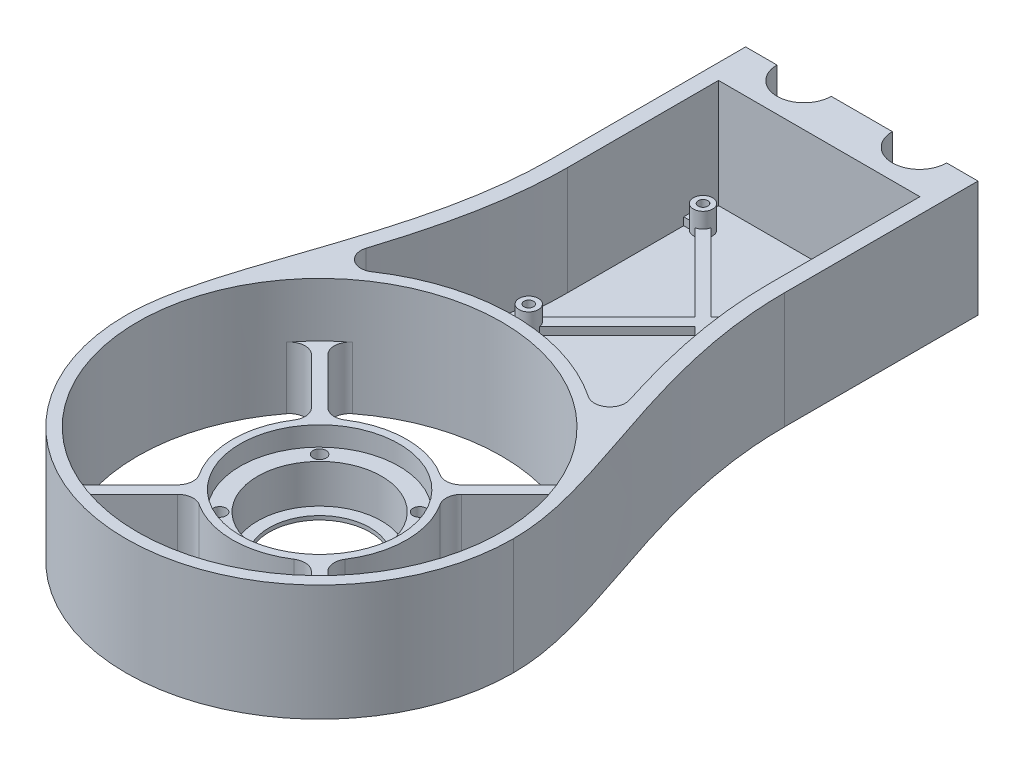
from build123d import *
from build123d.topology import SkipClean

# Parameters (mm, degrees)
EXTRUDE_1_DEPTH            = 30
CUT_EXTRUDE_1_DEPTH        = 209.32703380700454
SKETCH_3_R                 = 22.499999999999996
SKETCH_3_R_2               = 13.000000000000005
EXTRUDE_2_DEPTH            = 16
SKETCH_4_R                 = 20.499999999999996
CUT_EXTRUDE_2_DEPTH        = 5
SKETCH_5_R                 = 16.000000000000007
CUT_EXTRUDE_3_DEPTH        = 10
HOLE_WIZARD_M31_AT_2_COUNT = 2
HOLE_WIZARD_M31_AT_2_PITCH = 25.809397513308994
HOLE_WIZARD_M31_AT_3_COUNT = 2
HOLE_WIZARD_M31_AT_3_PITCH = 36.500000000000036
HOLE_WIZARD_M31_AT_4_COUNT = 2
HOLE_WIZARD_M31_AT_4_PITCH = 25.809397513308866
EXTRUDE_3_DEPTH            = 16
EXTRUDE_4_DEPTH            = 16
FILLET_1_R                 = 4
FILLET_2_R                 = 4
EXTRUDE_5_DEPTH            = 30
EXTRUDE_6_DEPTH            = 14
EXTRUDE_START              = -30
EXTRUDE_7_DEPTH            = 30
CUT_EXTRUDE_4_DEPTH        = 209.32703380700454
EXTRUDE_9_DEPTH            = 30
EXTRUDE_10_DEPTH           = 2
SKETCH_19_R                = 2.4999999999999996
SKETCH_19_R_2              = 2.5000000000000027
SKETCH_19_R_3              = 2.5
EXTRUDE_11_DEPTH           = 6
M3X0_51_D                  = 2.5
M3X0_51_DEPTH              = 6
M3X0_51_TIP                = 0.7510757737844503
EXTRUDE_12_DEPTH           = 2


with BuildPart() as part:
    # Эскиз1 → Бобышка-Вытянуть1 (new body)
    with BuildSketch(Plane(origin=(0, 0, 0), x_dir=(1, 0, 0), z_dir=(0, 1, 0))):
        with BuildLine():
            Line((0, 0), (8.1, 0))
            ThreePointArc((8.1, 0), (15.1, -6.999999999999998), (22.099999999999998, 0))
            Line((22.099999999999998, 0), (37.900000000000006, 0))
            ThreePointArc((37.900000000000006, 0), (44.9, -6.999999999999993), (51.9, 0))
            Line((51.9, 0), (60, 0))
            Line((60, 0), (60, -50))
            add(Edge.make_bspline(
                [(60, -50), (60, -86.11635365077277), (80.16072899532085, -116.6426083985747), (80, -140)],
                knots=[0, 0, 0, 0, 1, 1, 1, 1], degree=3))
            ThreePointArc((80, -140), (29.99999999999999, -190), (-20.000000000000004, -140))
            add(Edge.make_bspline(
                [(0, -50), (0, -86.11635365077277), (-20.160728995320852, -116.6426083985747), (-20.000000000000004, -140)],
                knots=[0, 0, 0, 0, 1, 1, 1, 1], degree=3))
            Line((0, -50), (0, 0))
        make_face()
    extrude(amount=EXTRUDE_1_DEPTH)

    # Эскиз2 → Вырез-Вытянуть1 (cut, through all)
    with BuildSketch(Plane.XZ):
        with BuildLine():
            Line((2.999999999999445, 50.000000000000114), (3, 3))
            Line((3, 3), (5.560607985830544, 3.0000000000000004))
            ThreePointArc((5.560607985830544, 3.0000000000000004), (15.1, 9.999999999999996), (24.639392014169452, 3))
            Line((24.639392014169452, 3), (35.36060798583055, 3.000000000000001))
            ThreePointArc((35.36060798583055, 3.000000000000001), (44.9, 9.999999999999995), (54.43939201416945, 3))
            Line((54.43939201416945, 3), (56.99999999999999, 3.0000000000000004))
            Line((56.99999999999999, 3.0000000000000004), (56.99999999999977, 49.999999999999964))
            add(Edge.make_bspline(
                [(56.99999999999977, 49.999999999999964), (56.999999999999766, 51.15761948444894), (57.04060731241618, 53.481441414304626), (57.273709046009834, 58.05633087995593), (57.83006206428006, 63.68575205723403), (58.858254923149566, 70.27885975955596), (60.62587825488252, 78.85472959222493), (63.422502324744904, 89.16282329636041), (67.22345269691866, 100.85676130834541), (70.98278726548399, 111.85118912341676), (73.68042570475818, 120.39952498600825), (75.34438659158283, 126.83896525592104), (76.29021877948416, 131.46025334650287), (76.78342190294366, 135.12322585437315), (76.97775852866562, 137.9483669686734), (77.0049038165422, 139.30439130408246), (76.99999885765422, 139.9896375455799)],
                knots=[0, 0, 0, 0, 0.03125495533209052, 0.06250991066418103, 0.12501982132836206, 0.18752973199254308, 0.2500396426567241, 0.37505946398508616, 0.5000792853134483, 0.6250991066418103, 0.7501189279701723, 0.8126288386343534, 0.8751387492985344, 0.9376486599627154, 0.968903615294806, 1.0001585706268965, 1.0001585706268965, 1.0001585706268965, 1.0001585706268965], degree=3))
            ThreePointArc((76.99999885765422, 139.9896375455799), (30.000000000044878, 186.99999999999957), (-16.999998857654532, 139.98963754566967))
            add(Edge.make_bspline(
                [(-16.999998857654532, 139.98963754566967), (-17.004903816544154, 139.30439130417213), (-16.977758528670723, 137.94836696876283), (-16.783421902954284, 135.12322585446222), (-16.290218779500016, 131.46025334659032), (-15.34438659160432, 126.83896525600643), (-13.680425704783374, 120.39952498608922), (-10.982787265509687, 111.85118912349087), (-7.223452696941435, 100.85676130840866), (-3.4225023247602575, 89.1628232964107), (-0.6258782548926894, 78.85472959226301), (1.1417450768448598, 70.27885975958334), (2.169937935716575, 63.68575205725274), (2.726290953988904, 58.056330879967035), (2.959392687583103, 53.48144141430967), (2.9999999999994453, 51.1576194844507), (2.999999999999445, 50.000000000000114)],
                knots=[-0.00015857062827955, -0.00015857062827955, -0.00015857062827955, -0.00015857062827955, 0.03109638470385419, 0.06235134003598793, 0.1248612507002554, 0.18737116136452286, 0.24988107202879034, 0.3749008933573253, 0.49992071468586025, 0.6249405360143951, 0.7499603573429301, 0.8124702680071976, 0.874980178671465, 0.9374900893357325, 0.9687450446678663, 1, 1, 1, 1], degree=3))
        make_face()
    extrude(amount=-CUT_EXTRUDE_1_DEPTH, mode=Mode.SUBTRACT)

    # Эскиз9 → Бобышка-Вытянуть3 (add)
    with SkipClean():  # the faces are left unmerged after this step: merging them gives an invalid solid
        with BuildSketch(Plane.XZ):
            with BuildLine():
                ThreePointArc((-10.590299410955694, 110.80363699425222), (29.999999999999805, 89.99999980965572), (70.59029941095437, 110.80363699425268))
                add(Edge.make_bspline(
                    [(70.59029941095437, 110.80363699425268), (70.69273970529346, 111.11282998358755), (71.96821202817154, 114.97382472799917), (73.68042570475818, 120.39952498600825), (75.34438659158283, 126.83896525592104), (76.29021877948416, 131.46025334650287), (76.78342190294366, 135.12322585437315), (76.97775852866562, 137.9483669686734), (77.0049038165422, 139.30439130408246), (76.99999885765422, 139.9896375455799)],
                    knots=[0.6142510234253288, 0.6142510234253288, 0.6142510234253288, 0.6142510234253288, 0.6250991066418103, 0.7501189279701723, 0.8126288386343534, 0.8751387492985344, 0.9376486599627154, 0.968903615294806, 1.0001585706268965, 1.0001585706268965, 1.0001585706268965, 1.0001585706268965], degree=3))
                ThreePointArc((76.99999885765422, 139.9896375455799), (29.99999999995513, 93.00000000000028), (-16.999998857654393, 139.98963754566967))
                add(Edge.make_bspline(
                    [(-16.999998857654393, 139.98963754566967), (-17.004903816544154, 139.30439130417213), (-16.977758528670723, 137.94836696876283), (-16.783421902954284, 135.12322585446222), (-16.290218779500016, 131.46025334659032), (-15.34438659160432, 126.83896525600643), (-13.680425704783374, 120.39952498608922), (-11.968212028189884, 114.97382472805306), (-10.692739705302907, 111.11282998361344), (-10.590299410955694, 110.80363699425222)],
                    knots=[-0.00015857062827955, -0.00015857062827955, -0.00015857062827955, -0.00015857062827955, 0.03109638470385419, 0.06235134003598793, 0.1248612507002554, 0.18737116136452286, 0.24988107202879034, 0.3749008933573253, 0.3857489765746533, 0.3857489765746533, 0.3857489765746533, 0.3857489765746533], degree=3))
            make_face()
        extrude(amount=-EXTRUDE_3_DEPTH)



with BuildPart() as body_2:
    # Эскиз3 → Бобышка-Вытянуть2 (new body)
    with BuildSketch(Plane.XZ):
        with Locations(Location((30, 140, 0), (0, 0, 270))):
            Circle(SKETCH_3_R)
        with Locations(Location((30, 140, 0), (0, 0, 270))):
            Circle(SKETCH_3_R_2, mode=Mode.SUBTRACT)
    extrude(amount=-EXTRUDE_2_DEPTH)

    # Эскиз4 → Вырез-Вытянуть2 (cut)
    with BuildSketch(Plane(origin=(0, 16, 0), x_dir=(1, 0, 0), z_dir=(0, 1, 0))):
        with Locations(Location((30, -140, 0), (0, 0, 270))):
            Circle(SKETCH_4_R)
    extrude(amount=-CUT_EXTRUDE_2_DEPTH, mode=Mode.SUBTRACT)

    # Эскиз5 → Вырез-Вытянуть3 (cut)
    with BuildSketch(Plane(origin=(0, 11, 0), x_dir=(1, 0, 0), z_dir=(0, 1, 0))):
        with Locations(Location((30, -140, 0), (0, 0, 270))):
            Circle(SKETCH_5_R)
    extrude(amount=-CUT_EXTRUDE_3_DEPTH, mode=Mode.SUBTRACT)

    # Эскиз7 → Отверстие с зазором M31 (revolve, cut)
    with BuildSketch(Plane(origin=(17.09530124334549, 11, 127.0953012433455), x_dir=(0, 0, 1), z_dir=(1, 0, 0))):
        Polygon((0, 0), (-2.69e-15, 11), (1.6999999999999966, 11), (1.699999999999988, -1.35e-15), align=None)
    hole_wizard_m31 = revolve(axis=Axis((17.09530124334549, 17.34999999999999, 127.0953012433455), (0, -1, 0)), mode=Mode.SUBTRACT)

    # Отверстие с зазором M31 at 2: Отверстие с зазором M31 ×2
    with Locations(*[(i * HOLE_WIZARD_M31_AT_2_PITCH, 0, 0) for i in range(1, HOLE_WIZARD_M31_AT_2_COUNT)]):
        add(hole_wizard_m31, mode=Mode.SUBTRACT)

    # Отверстие с зазором M31 at 3: Отверстие с зазором M31 ×2
    with Locations(*[Vector(0.7071067811865477, 0, 0.7071067811865475) * (i * HOLE_WIZARD_M31_AT_3_PITCH) for i in range(1, HOLE_WIZARD_M31_AT_3_COUNT)]):
        add(hole_wizard_m31, mode=Mode.SUBTRACT)

    # Отверстие с зазором M31 at 4: Отверстие с зазором M31 ×2
    with Locations(*[(0, 0, i * HOLE_WIZARD_M31_AT_4_PITCH) for i in range(1, HOLE_WIZARD_M31_AT_4_COUNT)]):
        add(hole_wizard_m31, mode=Mode.SUBTRACT)


with BuildPart() as part_1:
    with SkipClean():  # the faces are left unmerged after this step: merging them gives an invalid solid
        add(part.part)

        add(body_2.part)  # Бобышка-Вытянуть4 merges body 2
        # Эскиз10 → Бобышка-Вытянуть4 (add)
        with BuildSketch(Plane.XZ):
            with BuildLine():
                Line((13.061566249611717, 154.81011350677997), (-4.284838091182741, 172.14887054099086))
                ThreePointArc((-4.284838091182741, 172.14887054099086), (-3.2412744710377908, 173.22676137605254), (-2.163839456664804, 174.27079560509063))
                Line((-2.163839456664804, 174.27079560509063), (15.182490993971593, 156.93196464844726))
                ThreePointArc((15.182490993971593, 156.93196464844726), (14.08662392343936, 155.906428318323), (13.061566249611717, 154.81011350677997))
            make_face()
            with BuildLine():
                Line((15.189886493220024, 123.06156624961173), (-2.148870540990859, 105.71516190881728))
                ThreePointArc((-2.148870540990859, 105.71516190881728), (-3.2267613760524867, 106.75872552896217), (-4.270795605090482, 107.83616054333508))
                Line((-4.270795605090482, 107.83616054333508), (13.06803535155281, 125.18249099397156))
                ThreePointArc((13.06803535155281, 125.18249099397156), (14.093571681677025, 124.08662392343936), (15.189886493220024, 123.06156624961173))
            make_face()
            with BuildLine():
                Line((44.81011350677998, 156.9384337503883), (62.14887054099085, 174.2848380911828))
                ThreePointArc((62.14887054099085, 174.2848380911828), (63.22676137605259, 173.24127447103777), (64.27079560509073, 172.1638394566647))
                Line((64.27079560509073, 172.1638394566647), (46.931964648447305, 154.81750900602833))
                ThreePointArc((46.931964648447305, 154.81750900602833), (45.90642831832303, 155.9133760765606), (44.81011350677998, 156.9384337503883))
            make_face()
            with BuildLine():
                Line((46.93843375038829, 125.18988649322004), (64.28483809118275, 107.85112945900916))
                ThreePointArc((64.28483809118275, 107.85112945900916), (63.24127447103766, 106.77323862394736), (62.163839456664554, 105.72920439490919))
                Line((62.163839456664554, 105.72920439490919), (44.81750900602827, 123.06803535155267))
                ThreePointArc((44.81750900602827, 123.06803535155267), (45.91337607656057, 124.09357168167696), (46.93843375038829, 125.18988649322004))
            make_face()
        extrude(amount=-EXTRUDE_4_DEPTH)

    # Скругление1
    fillet_1_edges = [part_1.edges().sort_by_distance(p)[0] for p in [
        (70.59029941095437, 8, 110.80363699425268),
        (-10.590299410955694, 8, 110.80363699425222),
    ]]
    fillet(fillet_1_edges, radius=FILLET_1_R)

    # Скругление2
    fillet_2_edges = [part_1.edges().sort_by_distance(p)[0] for p in [
        (13.068035351552808, 8, 125.18249099397156),
        (-4.270795605090485, 8, 107.83616054333508),
        (13.061566249611715, 8, 154.81011350677997),
        (-4.284838091182738, 8, 172.14887054099086),
        (-2.1638394566648036, 8, 174.27079560509063),
        (15.182490993971593, 8, 156.93196464844726),
        (44.81011350677998, 8, 156.9384337503883),
        (62.148870540990856, 8, 174.2848380911828),
        (46.931964648447305, 8, 154.81750900602833),
        (64.27079560509073, 8, 172.1638394566647),
        (46.93843375038829, 8, 125.18988649322004),
        (64.28483809118275, 8, 107.85112945900917),
        (44.81750900602827, 8, 123.06803535155267),
        (15.189886493220023, 8, 123.06156624961173),
        (-2.1488705409908593, 8, 105.71516190881728),
        (62.16383945666455, 8, 105.72920439490919),
    ]]
    fillet(fillet_2_edges, radius=FILLET_2_R)

    # Эскиз11 → Бобышка-Вытянуть5 (add, through all)
    with BuildSketch(Plane(origin=(0, 30, 0), x_dir=(1, 0, 0), z_dir=(0, 1, 0))):
        with BuildLine():
            ThreePointArc((24.639392014169456, -3.000000000000001), (21.016079755907775, -8.062257768251904), (15.099999932545344, -9.999999999999998))
            Line((15.099999932545344, -9.999999999999998), (44.90000001649191, -9.999999999999998))
            ThreePointArc((44.90000001649191, -9.999999999999995), (38.98392022354849, -8.062257753176917), (35.36060798583055, -3.0000000000000004))
            Line((35.36060798583055, -3.000000000000001), (24.639392014169452, -2.9999999999999996))
        make_face()
        with BuildLine():
            ThreePointArc((54.43939201416945, -3.0000000000000013), (50.81607978974771, -8.062257743420174), (44.90000001649191, -9.999999999999995))
            Line((44.90000001649191, -9.999999999999998), (56.99999999999999, -9.999999999999998))
            Line((56.99999999999999, -9.999999999999998), (56.99999999999999, -3.0000000000000004))
            Line((56.99999999999999, -3.0000000000000004), (54.43939201416945, -3.0000000000000004))
        make_face()
        with BuildLine():
            Line((3.000000000000001, -3.0000000000000027), (3.000000000000001, -9.999999999999998))
            Line((3.000000000000001, -9.999999999999998), (15.099999932545344, -9.999999999999998))
            ThreePointArc((15.099999932545344, -9.999999999999998), (9.183920189708545, -8.062257728345193), (5.560607985830545, -3.0000000000000004))
            Line((5.560607985830544, -3.0000000000000004), (3.000000000000001, -3.0000000000000027))
        make_face()
    extrude(amount=-EXTRUDE_5_DEPTH)

    # Эскиз12 → Бобышка-Вытянуть6 (add)
    with BuildSketch(Plane(origin=(0, 16, 0), x_dir=(1, 0, 0), z_dir=(0, 1, 0))):
        with BuildLine():
            ThreePointArc((59.16935143725943, -99.39028495835004), (29.99999999999936, -89.9999998096564), (0.8306485627395179, -99.39028495835078))
            ThreePointArc((0.8306485627395179, -99.39028495835078), (-3.8552226296420704, -99.37671658564449), (-5.312887214055534, -94.92331486429973))
            add(Edge.make_bspline(
                [(-5.312887214055534, -94.92331486429973), (-5.942237739674335, -96.89165480215254), (-7.843811241515731, -102.67104176506649), (-10.982787265509687, -111.85118912349087), (-13.680425704783374, -120.39952498608922), (-15.34438659160432, -126.83896525600643), (-16.290218779500016, -131.46025334659032), (-16.783421902954284, -135.12322585446222), (-16.977758528670723, -137.94836696876283), (-17.004903816544154, -139.30439130417213), (-16.99999885765474, -139.98963754566967)],
                knots=[-0.00015857062827955, -0.00015857062827955, -0.00015857062827955, -0.00015857062827955, 0.06296962095485116, 0.18798944228338613, 0.31300926361192105, 0.3755191742761885, 0.438029084940456, 0.5005389956047235, 0.5317939509368572, 0.563048906268991, 0.563048906268991, 0.563048906268991, 0.563048906268991], degree=3))
            ThreePointArc((-16.99999885765474, -139.98963754566967), (29.99999999995513, -93.00000000000043), (76.99999885765422, -139.9896375455799))
            add(Edge.make_bspline(
                [(76.99999885765422, -139.9896375455799), (77.0049038165422, -139.30439130408246), (76.97775852866562, -137.9483669686734), (76.78342190294366, -135.12322585437315), (76.29021877948416, -131.46025334650287), (75.34438659158283, -126.83896525592104), (73.68042570475818, -120.39952498600825), (70.98278726548399, -111.85118912341676), (67.84381124149844, -102.67104176501897), (65.94223773966633, -96.89165480213047), (65.31288721405446, -94.92331486429903)],
                knots=[0.4369510937310026, 0.4369510937310026, 0.4369510937310026, 0.4369510937310026, 0.46820604906309315, 0.4994610043951837, 0.5619709150593647, 0.6244808257235457, 0.6869907363877268, 0.8120105577160888, 0.9370303790444509, 1.0001585706268965, 1.0001585706268965, 1.0001585706268965, 1.0001585706268965], degree=3))
            ThreePointArc((65.31288721405446, -94.92331486429903), (63.855222629640906, -99.37671658564365), (59.16935143725943, -99.39028495835004))
        make_face()
    extrude(amount=EXTRUDE_6_DEPTH)

    # Эскиз13 → Бобышка-Вытянуть7 (add)
    with BuildSketch(Plane(origin=(0, 30, 0), x_dir=(1, 0, 0), z_dir=(0, 1, 0)).offset(EXTRUDE_START)):
        with BuildLine():
            Line((3.9999999999992784, -50.0000000000001), (3.999999999999895, -10.999999999999996))
            Line((3.999999999999895, -10.999999999999996), (55.99999999999998, -10.999999999999996))
            Line((55.99999999999998, -10.999999999999996), (55.99999999999991, -49.99999999999998))
            add(Edge.make_bspline(
                [(55.99999999999991, -49.99999999999998), (55.99999999999991, -52.03498068113325), (56.12527058577417, -56.13193535820143), (56.819212399121525, -64.08850039677553), (58.41081044935653, -73.7477782372734), (60.67836350111951, -82.95184755755167), (62.73749964431051, -90.06762105355448), (63.80856926980304, -93.50200234801329), (64.36039029638012, -95.22786309007068)],
                knots=[0, 0, 0, 0, 0.05461888671637527, 0.10923777343275054, 0.21847554686550108, 0.3277133202982516, 0.3823322070146269, 0.43695109373100216, 0.43695109373100216, 0.43695109373100216, 0.43695109373100216], degree=3))
            Line((64.36039029638012, -95.22786309007068), (65.16614916399801, -97.74793305879278))
            ThreePointArc((65.16614916399801, -97.74793305879278), (65.49751290253579, -96.34902670789197), (65.31288721405447, -94.92331486429906))
            add(Edge.make_bspline(
                [(56.99999999999977, -49.999999999999964), (56.999999999999766, -51.15761948444894), (57.04060731241618, -53.481441414304626), (57.273709046009834, -58.05633087995593), (57.83006206428006, -63.68575205723403), (58.858254923149566, -70.27885975955596), (60.62587825488252, -78.85472959222493), (62.85764527026983, -87.08081323654652), (64.69586447452775, -92.99353098181192), (65.31288721405447, -94.92331486429906)],
                knots=[0, 0, 0, 0, 0.03125495533209052, 0.06250991066418103, 0.12501982132836206, 0.18752973199254308, 0.2500396426567241, 0.37505946398508616, 0.4369510937310029, 0.4369510937310029, 0.4369510937310029, 0.4369510937310029], degree=3))
            Line((56.99999999999977, -49.999999999999964), (56.99999999999996, -9.999999999999998))
            Line((56.99999999999996, -9.999999999999998), (2.9999999999999174, -9.999999999999995))
            Line((2.9999999999999174, -9.999999999999995), (2.999999999999445, -50.000000000000114))
            add(Edge.make_bspline(
                [(-5.312887214055517, -94.92331486429967), (-4.695864474533832, -92.99353098182853), (-2.857645270278764, -87.08081323657458), (-0.6258782548926894, -78.85472959226301), (1.1417450768448598, -70.27885975958334), (2.169937935716575, -63.68575205725274), (2.726290953988904, -58.056330879967035), (2.959392687583103, -53.48144141430967), (2.9999999999994453, -51.1576194844507), (2.999999999999445, -50.000000000000114)],
                knots=[0.5630489062689918, 0.5630489062689918, 0.5630489062689918, 0.5630489062689918, 0.6249405360143951, 0.7499603573429301, 0.8124702680071976, 0.874980178671465, 0.9374900893357325, 0.9687450446678663, 1, 1, 1, 1], degree=3))
            ThreePointArc((-5.312887214055517, -94.92331486429967), (-5.4975129025367595, -96.34902670789273), (-5.166149163999231, -97.74793305879379))
            Line((-5.166149163999231, -97.74793305879379), (-4.360390296381386, -95.22786309007161))
            add(Edge.make_bspline(
                [(-4.360390296381386, -95.22786309007161), (-3.8085692698043276, -93.50200234801419), (-2.737499644311918, -90.06762105355533), (-0.6783635011204932, -82.95184755755248), (1.5891895506421023, -73.74777823727402), (3.1807876008779727, -64.08850039677573), (3.8747294142246784, -56.131935358201844), (3.99999999999928, -52.03498068113343), (3.9999999999992784, -50.0000000000001)],
                knots=[0.5630489062689885, 0.5630489062689885, 0.5630489062689885, 0.5630489062689885, 0.6176677929853649, 0.6722866797017414, 0.7815244531344943, 0.8907622265672471, 0.9453811132836236, 1, 1, 1, 1], degree=3))
        make_face()
    extrude(amount=EXTRUDE_7_DEPTH)

    # Эскиз14 → Вырез-Вытянуть4 (cut, through all)
    with BuildSketch(Plane(origin=(0, 30, 0), x_dir=(1, 0, 0), z_dir=(0, 1, 0))):
        with BuildLine():
            Line((3.9999999999992784, -50.0000000000001), (55.99999999999991, -49.99999999999998))
            add(Edge.make_bspline(
                [(55.99999999999991, -49.99999999999998), (55.99999999999991, -52.03498068113325), (56.12527058577417, -56.13193535820143), (56.819212399121525, -64.08850039677553), (58.41081044935653, -73.7477782372734), (60.67836350111951, -82.95184755755167), (62.73749964431051, -90.06762105355448), (63.80856926980304, -93.50200234801329), (64.36039029638012, -95.22786309007068)],
                knots=[0, 0, 0, 0, 0.05461888671637527, 0.10923777343275054, 0.21847554686550108, 0.3277133202982516, 0.3823322070146269, 0.43695109373100216, 0.43695109373100216, 0.43695109373100216, 0.43695109373100216], degree=3))
            Line((64.36039029638012, -95.22786309007068), (68.45994864398259, -108.0495325646622))
            ThreePointArc((68.45994864398259, -108.0495325646622), (29.99999999999889, -89.9999998096564), (-8.459948643984049, -108.04953256466388))
            Line((-8.459948643984049, -108.04953256466388), (-4.360390296381386, -95.22786309007161))
            add(Edge.make_bspline(
                [(-4.360390296381386, -95.22786309007161), (-3.8085692698043276, -93.50200234801419), (-2.737499644311918, -90.06762105355533), (-0.6783635011204932, -82.95184755755248), (1.5891895506421023, -73.74777823727402), (3.1807876008779727, -64.08850039677573), (3.8747294142246784, -56.131935358201844), (3.99999999999928, -52.03498068113343), (3.9999999999992784, -50.0000000000001)],
                knots=[0.5630489062689885, 0.5630489062689885, 0.5630489062689885, 0.5630489062689885, 0.6176677929853649, 0.6722866797017414, 0.7815244531344943, 0.8907622265672471, 0.9453811132836236, 1, 1, 1, 1], degree=3))
        make_face()
    extrude(amount=-CUT_EXTRUDE_4_DEPTH, mode=Mode.SUBTRACT)

    # Эскиз15 → Бобышка-Вытянуть9 (add)
    with BuildSketch(Plane(origin=(0, 30, 0), x_dir=(1, 0, 0), z_dir=(0, 1, 0))):
        with BuildLine():
            Line((-4.360390296381386, -95.22786309007161), (-8.459948643984049, -108.04953256466388))
            ThreePointArc((-8.459948643984049, -108.04953256466388), (-3.5312054010374823, -102.91013233526172), (2.0776304150828864, -98.52300281122487))
            ThreePointArc((2.07763041508289, -98.52300281122487), (-2.5353445930742455, -98.42034842289144), (-3.9825043477067164, -94.03904667638977))
            add(Edge.make_bspline(
                [(-4.360390296381386, -95.22786309007161), (-4.233592316694429, -94.83129310673598), (-4.107654237723681, -94.43518089835217), (-3.98250434770692, -94.03904667639037)],
                knots=[0.5630489062689885, 0.5630489062689885, 0.5630489062689885, 0.5630489062689885, 0.5755992879232479, 0.5755992879232479, 0.5755992879232479, 0.5755992879232479], degree=3))
        make_face()
        with BuildLine():
            Line((68.45994864398261, -108.04953256466219), (64.36039029638012, -95.22786309007068))
            add(Edge.make_bspline(
                [(63.98253813414828, -94.03915361981963), (64.10767690386872, -94.43525219001346), (64.23360372714463, -94.83132879375911), (64.36039029638012, -95.22786309007068)],
                knots=[0.4244018414758169, 0.4244018414758169, 0.4244018414758169, 0.4244018414758169, 0.43695109373100216, 0.43695109373100216, 0.43695109373100216, 0.43695109373100216], degree=3))
            ThreePointArc((63.982538134148065, -94.03915361981899), (62.535301459710944, -98.42038247928511), (57.922370806697025, -98.52300363372812))
            ThreePointArc((57.92237080669702, -98.52300363372812), (63.53120594731105, -102.91013282912198), (68.45994864398261, -108.04953256466219))
        make_face()
    extrude(amount=-EXTRUDE_9_DEPTH)

    # Эскиз16 → Бобышка-Вытянуть10 (add)
    with BuildSketch(Plane.XZ):
        Polygon((-7.8524647657984, 101.93517402749758), (-2.0682379994428626, 81.42746094678252), (2.4013917745591415, 58.81639267830183), (2.4013917745591415, 39.097437792998896), (2.4013917745591415, 22.53351568934444), (2.4013917745591415, 9.387545765809158), (57.35154605493661, 9.387545765809158), (57.35154605493661, 36.73116320676255), (57.35154605493661, 56.975956889006895), (62.60993402435075, 81.42746094678252), (67.0201949019239, 101.93517402749758), (62.60993402435075, 101.93517402749758), (57.35154605493661, 100.89572524284594), (53.10461288062748, 97.8523070484284), (47.493444525620525, 95.40639704359529), (40.92861683359864, 92.5447866416201), (34.93130146834046, 92.5447866416201), (28.840892836007253, 91.3408686561589), (21.73358788745398, 92.86932133326714), (13.415834781085877, 94.65808544216351), (5.092688811679992, 97.8523070484284), (-1.046943422200762, 101.93517402749758), align=None)
    extrude(amount=-EXTRUDE_10_DEPTH)

    # Эскиз19 → Бобышка-Вытянуть11 (add)
    with BuildSketch(Plane(origin=(0, 2, 0), x_dir=(1, 0, 0), z_dir=(0, 1, 0))):
        with Locations(Location((7.499999999999693, -18.499999999999996, 0), (0, 0, 90))):
            Circle(SKETCH_19_R)
        with Locations(Location((52.4999999999997, -18.499999999999996, 0), (0, 0, 90))):
            Circle(SKETCH_19_R_2)
        with Locations(Location((52.49999999999971, -63.5, 0), (0, 0, 90))):
            Circle(SKETCH_19_R_2)
        with Locations(Location((7.499999999999699, -63.5, 0), (0, 0, 90))):
            Circle(SKETCH_19_R_3)
    extrude(amount=EXTRUDE_11_DEPTH)

    # Отверстие обработанное метчиком M3x0.51
    with Locations(Plane(origin=(0, 8, 0), x_dir=(1, 0, 0), z_dir=(0, 1, 0))):
        with Locations((7.5, -18.5), (52.5, -18.5), (52.5, -63.5), (7.5, -63.5)):
            Hole(M3X0_51_D / 2, depth=M3X0_51_DEPTH)
            with Locations((0, 0, -(M3X0_51_DEPTH + M3X0_51_TIP / 2))):  # 118° drill point
                Cone(0, M3X0_51_D / 2, M3X0_51_TIP, mode=Mode.SUBTRACT)

    # Эскиз22 → Бобышка-Вытянуть12 (add)
    with BuildSketch(Plane(origin=(0, 2, 0), x_dir=(1, 0, 0), z_dir=(0, 1, 0))):
        with BuildLine():
            ThreePointArc((9.97487373415261, -18.85355339059327), (9.267766952966062, -20.267766952966365), (7.853553390592965, -20.974873734152915))
            Line((7.853553390592965, -20.974873734152915), (27.878679656440053, -41.00000000000001))
            Line((27.878679656440053, -41.00000000000001), (7.853553390592972, -61.02512626584708))
            ThreePointArc((7.853553390592972, -61.02512626584708), (9.26776695296607, -61.73223304703363), (9.974873734152618, -63.14644660940673))
            Line((9.974873734152617, -63.14644660940673), (29.999999999999694, -43.12132034355966))
            Line((29.999999999999694, -43.12132034355966), (50.02512626584679, -63.146446609406745))
            ThreePointArc((50.02512626584679, -63.146446609406745), (50.732233047033326, -61.732233047033645), (52.14644660940642, -61.025126265847085))
            Line((52.14644660940642, -61.02512626584708), (32.12132034355934, -41))
            Line((32.12132034355934, -41), (52.14644660940643, -20.97487373415292))
            ThreePointArc((52.14644660940643, -20.974873734152915), (50.73223304703333, -20.26776695296637), (50.02512626584679, -18.853553390593273))
            Line((50.02512626584679, -18.853553390593273), (29.999999999999705, -38.87867965644036))
            Line((29.99999999999971, -38.87867965644036), (9.974873734152608, -18.85355339059327))
        make_face()
        with BuildLine():
            Line((3.999999999999776, -19.999999999999996), (5.4999999999996945, -19.999999999999996))
            ThreePointArc((5.4999999999996945, -19.999999999999996), (4.9999999999996945, -18.499999999999993), (5.499999999999696, -16.999999999999993))
            Line((5.4999999999996945, -16.999999999999993), (3.999999999999776, -16.999999999999993))
            Line((3.999999999999776, -16.999999999999993), (3.999999999999776, -19.999999999999996))
        make_face()
        with BuildLine():
            ThreePointArc((5.499999999999707, -65.00000000000001), (4.999999999999698, -63.500000000000014), (5.4999999999996865, -62.000000000000014))
            Line((5.499999999999686, -62.000000000000014), (3.3150022080520247, -62.000000000000234))
            add(Edge.make_bspline(
                [(2.940902429424268, -65.00000000033711), (3.0739080344752345, -64.03161035225473), (3.199237612352327, -63.03166786483183), (3.3120087197819035, -62.02675817436333), (3.315002208008357, -62.00000000039057)],
                knots=[0.8636467637840218, 0.8636467637840218, 0.8636467637840218, 0.8636467637840218, 0.8907622265672471, 0.8915038922890043, 0.8915038922890043, 0.8915038922890043, 0.8915038922890043], degree=3))
            Line((2.9409024294705666, -65.00000000000001), (5.499999999999707, -65.00000000000001))
        make_face()
        with BuildLine():
            Line((55.999999999999964, -16.999999999999993), (54.4999999999997, -16.999999999999993))
            ThreePointArc((54.4999999999997, -16.999999999999993), (54.9999999999997, -18.499999999999996), (54.4999999999997, -20))
            Line((54.4999999999997, -19.999999999999996), (55.999999999999964, -19.999999999999996))
            Line((55.999999999999964, -19.999999999999996), (55.999999999999964, -16.999999999999993))
        make_face()
        with BuildLine():
            ThreePointArc((54.49999999999973, -62.00000000000002), (54.99999999999971, -63.50000000000002), (54.4999999999997, -65.00000000000001))
            Line((54.4999999999997, -65.00000000000001), (57.059097570528714, -65.00000000000001))
            add(Edge.make_bspline(
                [(56.684997791955496, -62.00000000007417), (56.687991280193664, -62.02675817415233), (56.80076238762177, -63.03166786461972), (56.92609196549733, -64.03161035204154), (57.05909757053132, -65.00000000001907)],
                knots=[0.10849610770807283, 0.10849610770807283, 0.10849610770807283, 0.10849610770807283, 0.10923777343275054, 0.13635323621300985, 0.13635323621300985, 0.13635323621300985, 0.13635323621300985], degree=3))
            Line((56.684997791947225, -62.000000000000206), (54.49999999999972, -62.000000000000014))
        make_face()
    extrude(amount=EXTRUDE_12_DEPTH)


solid = part_1.part
